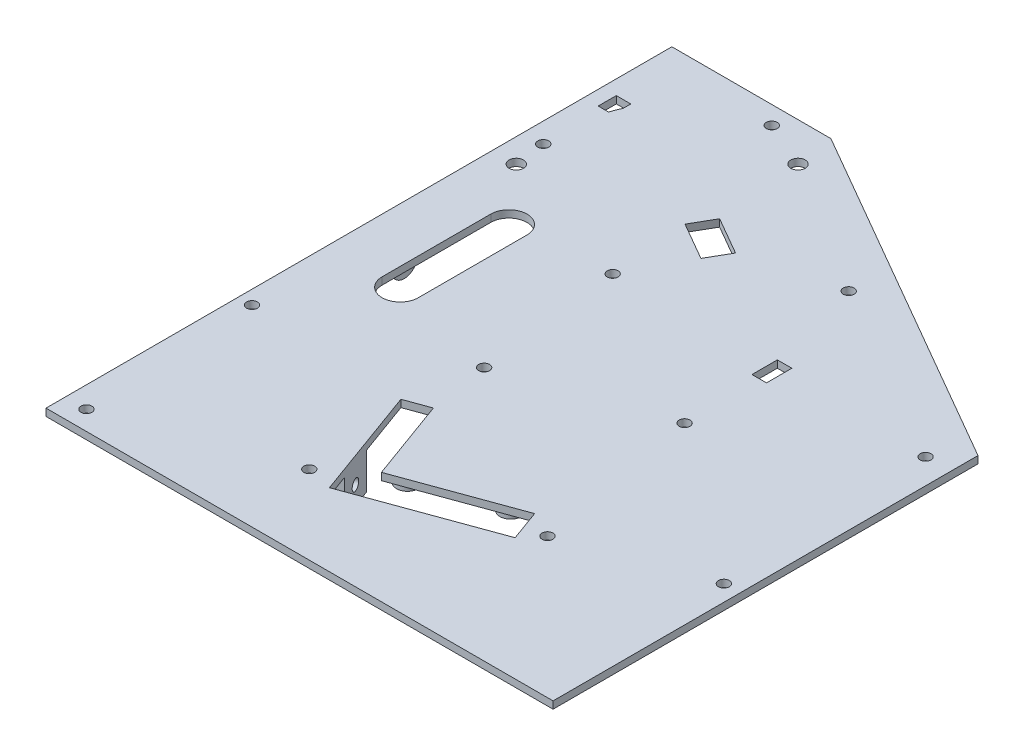
from build123d import *

# Parameters (mm, degrees)
SKETCH1_W                       = 140
SKETCH1_H                       = 200
BOSS_EXTRUDE1_DEPTH             = 2
SKETCH4_R                       = 20
CUT_EXTRUDE1_DEPTH              = 1
CUT_EXTRUDE2_REACH              = 4
SKETCH6_R                       = 2
SKETCH2_W                       = 4.004504799
SKETCH2_H                       = 7.007808652
CUT_EXTRUDE4_DEPTH              = 1
CUT_EXTRUDE4_DEPTH_BACK         = 3
CUT_EXTRUDE5_DEPTH              = 2
SKETCH8_W                       = 10
SKETCH8_H                       = 10
SKETCH8_R                       = 1.5
BOSS_EXTRUDE2_DEPTH             = 4
BOSS_EXTRUDE4_DEPTH             = 5
BOSS_EXTRUDE5_DEPTH             = 23
CUT_EXTRUDE6_DEPTH              = 10
F_3_0MM_CLEARANCE_DOWEL_HOLE1_D = 3
CUT_EXTRUDE7_DEPTH              = 26
SKETCH18_W                      = 140
SKETCH18_H                      = 27.200459883
CUT_EXTRUDE8_DEPTH              = 26
CUT_EXTRUDE9_DEPTH              = 32
SKETCH20_R                      = 1.5
BOSS_EXTRUDE7_DEPTH             = 10
LPATTERN1_COUNT                 = 3
LPATTERN1_PITCH                 = 75
CUT_EXTRUDE10_DEPTH             = 2


with BuildPart() as part:
    # Sketch1 → Boss-Extrude1 (new body)
    with BuildSketch(Plane(origin=(0, 0, 0), x_dir=(1, 0, 0), z_dir=(0, 1, 0))):
        Rectangle(SKETCH1_W, SKETCH1_H)
    extrude(amount=BOSS_EXTRUDE1_DEPTH)

    # Sketch4 → Cut-Extrude1 (cut)
    with BuildSketch(Plane.XZ):
        with Locations((-43.968804066, -69.910192249)):
            Circle(SKETCH4_R)
    extrude(amount=-CUT_EXTRUDE1_DEPTH, mode=Mode.SUBTRACT)

    # Sketch6 → Cut-Extrude2 (cut, up to next)
    with BuildSketch(Plane.XZ, mode=Mode.PRIVATE) as cut_extrude2_sk1:
        with Locations((-63.414240549, -50.464755767)):
            Circle(SKETCH6_R)
    cut_extrude2_tool1 = extrude(cut_extrude2_sk1.sketch, amount=-CUT_EXTRUDE2_REACH, mode=Mode.PRIVATE) & part.part
    add(cut_extrude2_tool1.solids().sort_by_distance((-63.414241, 0, -50.464756))[0], mode=Mode.SUBTRACT)
    # Sketch6 → Cut-Extrude2 (cut, up to next)
    with BuildSketch(Plane.XZ, mode=Mode.PRIVATE) as cut_extrude2_sk2:
        with Locations((-24.523367583, -89.355628732)):
            Circle(SKETCH6_R)
    cut_extrude2_tool2 = extrude(cut_extrude2_sk2.sketch, amount=-CUT_EXTRUDE2_REACH, mode=Mode.PRIVATE) & part.part
    add(cut_extrude2_tool2.solids().sort_by_distance((-24.523368, 0, -89.355629))[0], mode=Mode.SUBTRACT)

    # Sketch2 → Cut-Extrude4 (cut, two sides)
    with BuildSketch(Plane(origin=(0, 2, 0), x_dir=(1, 0, 0), z_dir=(0, 1, 0))) as cut_extrude4_sk:
        Polygon((-15.389965741, 53.410192249), (-11.889965741, 59.472370076), (-22.282270586, 65.472370076), (-25.782270586, 59.410192249), align=None)
        with BuildLine():
            Line((-62, 80.655444566), (-66, 80.655444566))
            Line((-66, 80.655444566), (-66, 75.655444566))
            Line((-66, 75.655444566), (-63.125841306, 75.655444566))
            ThreePointArc((-63.125841306, 75.655444566), (-62.619676759, 77.131338127), (-62, 78.563282633))
            Line((-62, 78.563282633), (-62, 80.655444566))
        make_face()
        with Locations((21.429491924, 36.193920339)):
            Rectangle(SKETCH2_W, SKETCH2_H)
    extrude(amount=CUT_EXTRUDE4_DEPTH, mode=Mode.SUBTRACT)
    extrude(cut_extrude4_sk.sketch, amount=-CUT_EXTRUDE4_DEPTH_BACK, mode=Mode.SUBTRACT)

    # Sketch7 → Cut-Extrude5 (cut)
    with BuildSketch(Plane(origin=(0, 2, 0), x_dir=(1, 0, 0), z_dir=(0, 1, 0))):
        Polygon((-11.836174724, -52.702068722), (-14.572335871, -45.184527756), (23.015368961, -31.503722023), (25.751530107, -39.021262989), align=None)
        Polygon((-14.914356014, -44.244835135), (22.673348817, -30.564029402), (23.015368961, -31.503722023), (-14.572335871, -45.184527756), align=None)
    extrude(amount=-CUT_EXTRUDE5_DEPTH, mode=Mode.SUBTRACT)

    # Sketch8 → Boss-Extrude2 (add)
    with BuildSketch(Plane(origin=(10.197981142, 0, -3.711761585), x_dir=(0.342020143, 0, 0.939692621), z_dir=(-0.939692621, 0, 0.342020143))):
        with Locations((33.475534903, -5)):
            Rectangle(SKETCH8_W, SKETCH8_H)
        with Locations((33.475534903, -5)):
            Circle(SKETCH8_R, mode=Mode.SUBTRACT)
    boss_extrude2 = extrude(amount=-BOSS_EXTRUDE2_DEPTH)

    # Mirror1: Boss-Extrude2 across plane
    add(boss_extrude2.mirror(Plane(origin=(-8.595871274, 0, 3.128641281), x_dir=(0.342020143, 0, 0.939692621), z_dir=(-0.939692621, 0, 0.342020143))))

    # Sketch9 → Boss-Extrude4 (add)
    with BuildSketch(Plane(origin=(0, 0, 0), x_dir=(-1, 0, 0), z_dir=(0, -1, 0))):
        with BuildLine():
            Line((18.286185593, -17.803458652), (12.129823014, -34.717925827))
            ThreePointArc((12.129823014, -34.717925827), (8.284684721, -36.510943259), (6.491667289, -32.665804967))
            Line((6.491667289, -32.665804967), (12.648029869, -15.751337793))
            ThreePointArc((12.648029869, -15.751337793), (16.493168161, -13.95832036), (18.286185593, -17.803458652))
        make_face()
        with BuildLine():
            Line((16.406800352, -17.119418366), (10.250437772, -34.03388554))
            ThreePointArc((10.250437772, -34.03388554), (8.968725008, -34.631558017), (8.37105253, -33.349845253))
            Line((8.37105253, -33.349845253), (14.52741511, -16.435378079))
            ThreePointArc((14.52741511, -16.435378079), (15.809127874, -15.837705602), (16.406800352, -17.119418366))
        make_face(mode=Mode.SUBTRACT)
    boss_extrude4 = extrude(amount=BOSS_EXTRUDE4_DEPTH)

    # Mirror2: Boss-Extrude4 across plane
    add(boss_extrude4.mirror(Plane(origin=(-8.595871274, 0, 3.128641281), x_dir=(0.342020143, 0, 0.939692621), z_dir=(-0.939692621, 0, 0.342020143))))

    # Sketch10 → Boss-Extrude5 (add)
    with BuildSketch(Plane.XZ):
        Polygon((-28.465283288, -55.763077932), (-19.80502925, -50.763077932), (-23.80502925, -43.834874702), (-32.465283288, -48.834874702), align=None)
    boss_extrude5 = extrude(amount=BOSS_EXTRUDE5_DEPTH)

    # Sketch11 → Cut-Extrude6 (cut)
    with BuildSketch(Plane(origin=(-45.495083508, 0, -26.26659871), x_dir=(-0.5, 0, 0.866025404), z_dir=(-0.866025404, 0, -0.5))):
        with BuildLine():
            Line((-30.059600438, -20.004300783), (-30.059600438, -16.004300783))
            ThreePointArc((-30.059600438, -16.004300783), (-29.059600438, -15.004300783), (-28.059600438, -16.004300783))
            Line((-28.059600438, -16.004300783), (-28.059600438, -20.004300783))
            ThreePointArc((-28.059600438, -20.004300783), (-29.059600438, -21.004300783), (-30.059600438, -20.004300783))
        make_face()
        with BuildLine():
            Line((-30.059600438, -6.504300783), (-30.059600438, -2.504300783))
            ThreePointArc((-30.059600438, -2.504300783), (-29.059600438, -1.504300783), (-28.059600438, -2.504300783))
            Line((-28.059600438, -2.504300783), (-28.059600438, -6.504300783))
            ThreePointArc((-28.059600438, -6.504300783), (-29.059600438, -7.504300783), (-30.059600438, -6.504300783))
        make_face()
    cut_extrude6 = extrude(amount=-CUT_EXTRUDE6_DEPTH, mode=Mode.SUBTRACT)

    # Mirror3: Boss-Extrude5, Cut-Extrude6 across plane
    add(boss_extrude5.mirror(Plane(origin=(21.029800219, 0, -36.424682453), x_dir=(0.866025404, 0, 0.5), z_dir=(-0.5, 0, 0.866025404))))
    add(cut_extrude6.mirror(Plane(origin=(21.029800219, 0, -36.424682453), x_dir=(0.866025404, 0, 0.5), z_dir=(-0.5, 0, 0.866025404))), mode=Mode.SUBTRACT)

    # Ø3.0mm Clearance Dowel Hole1 (through all)
    with Locations(Plane(origin=(-89.742029537, 2, 119.499715795), x_dir=(1, 0, 0), z_dir=(0, 1, 0))):
        with Locations((23.542258378, 99.781049413), (25.594379238, 52.014538143), (70.699625036, 68.431505023), (70.526889417, 116.882056579), (111.491838386, 131.259989766), (119.586439667, 85.314281565), (155.294759257, 98.311047011), (152.806439447, 156.481766603), (65.878236217, 157.017664987), (102.576966028, 185.481766603), (52.347492608, 214.481766603), (25.242029537, 178.499715795)):
            Hole(F_3_0MM_CLEARANCE_DOWEL_HOLE1_D / 2)

    # Sketch16 → Cut-Extrude7 (cut, through all)
    with BuildSketch(Plane(origin=(0, 2, 0), x_dir=(1, 0, 0), z_dir=(0, 1, 0))):
        Polygon((-43.621778265, 110.124355653), (83.026139699, 110.124355653), (83.026139699, 36.903214828), (77, 40.483339502), align=None)
    extrude(amount=-CUT_EXTRUDE7_DEPTH, mode=Mode.SUBTRACT)

    # Sketch18 → Cut-Extrude8 (cut, through all)
    with BuildSketch(Plane(origin=(0, 2, 0), x_dir=(1, 0, 0), z_dir=(0, 1, 0))):
        with Locations((0, -86.399770058)):
            Rectangle(SKETCH18_W, SKETCH18_H)
    extrude(amount=-CUT_EXTRUDE8_DEPTH, mode=Mode.SUBTRACT)

    # Sketch19 → Cut-Extrude9 (cut, through all)
    with BuildSketch(Plane(origin=(-89.742029537, 8, 119.499715795), x_dir=(1, 0, 0), z_dir=(0, 1, 0))):
        with BuildLine():
            Line((44.742029537, 154.499715795), (44.742029537, 124.499715795))
            ThreePointArc((44.742029537, 124.499715795), (39.742029537, 119.499715795), (34.742029537, 124.499715795))
            Line((34.742029537, 124.499715795), (34.742029537, 154.499715795))
            ThreePointArc((34.742029537, 154.499715795), (39.742029537, 159.499715795), (44.742029537, 154.499715795))
        make_face()
    extrude(amount=-CUT_EXTRUDE9_DEPTH, mode=Mode.SUBTRACT)

    # Sketch20 → Boss-Extrude7 (add)
    with BuildSketch(Plane.ZY.offset(70)):
        with BuildLine():
            Line((55.358547654, -3), (55.358547654, 0))
            Line((55.358547654, 0), (62.358547654, 0))
            Line((62.358547654, 0), (62.358547654, -3))
            ThreePointArc((62.358547654, -3), (58.858547654, -6.5), (55.358547654, -3))
        make_face()
        with Locations((58.858547654, -3)):
            Circle(SKETCH20_R, mode=Mode.SUBTRACT)
    boss_extrude7 = extrude(amount=-BOSS_EXTRUDE7_DEPTH)

    # LPattern1: Boss-Extrude7 ×3
    with Locations(*[(0, 0, -i * LPATTERN1_PITCH) for i in range(1, LPATTERN1_COUNT)]):
        add(boss_extrude7)

    # Sketch22 → Cut-Extrude10 (cut)
    with BuildSketch(Plane(origin=(0, 2, 0), x_dir=(1, 0, 0), z_dir=(0, 1, 0))):
        Polygon((-14.914356014, -44.244835135), (-8.336507669, -41.850694132), (-16.544991108, -19.298071233), (-23.122839454, -21.692212236), align=None)
    extrude(amount=-CUT_EXTRUDE10_DEPTH, mode=Mode.SUBTRACT)


solid = part.part
